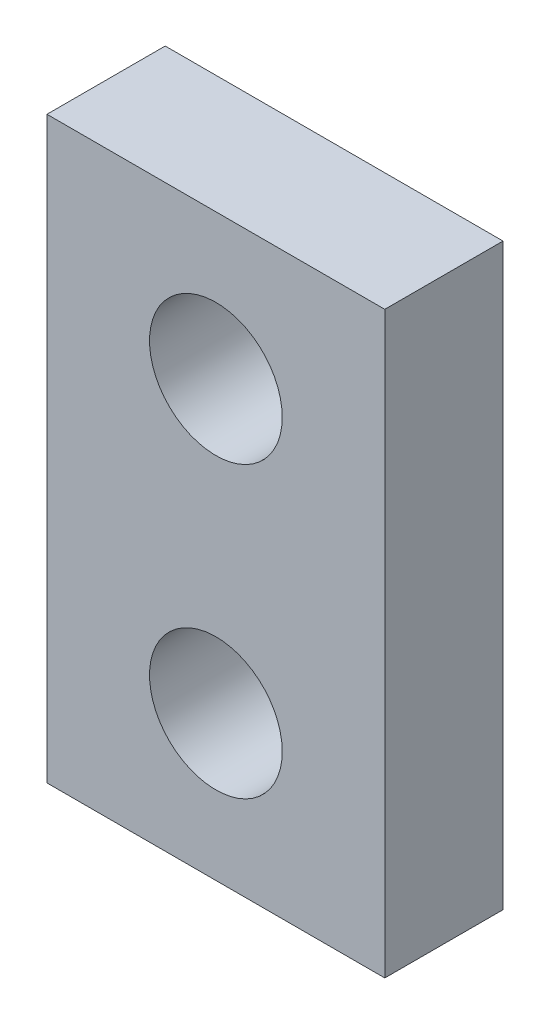
from build123d import *

# Parameters (mm, degrees)
SKETCH1_W                 = 7
SKETCH1_H                 = 12
SKETCH1_R                 = 1.375
REARTAILLIGHTSPACER_DEPTH = 2.45


with BuildPart() as part:
    # Sketch1 → rearTailLightSpacer (new body)
    with BuildSketch(Plane.XY):
        with Locations((3.5, 6)):
            Rectangle(SKETCH1_W, SKETCH1_H)
        with Locations((3.5, 3)):
            Circle(SKETCH1_R, mode=Mode.SUBTRACT)
        with Locations((3.5, 9)):
            Circle(SKETCH1_R, mode=Mode.SUBTRACT)
    extrude(amount=REARTAILLIGHTSPACER_DEPTH)


solid = part.part
